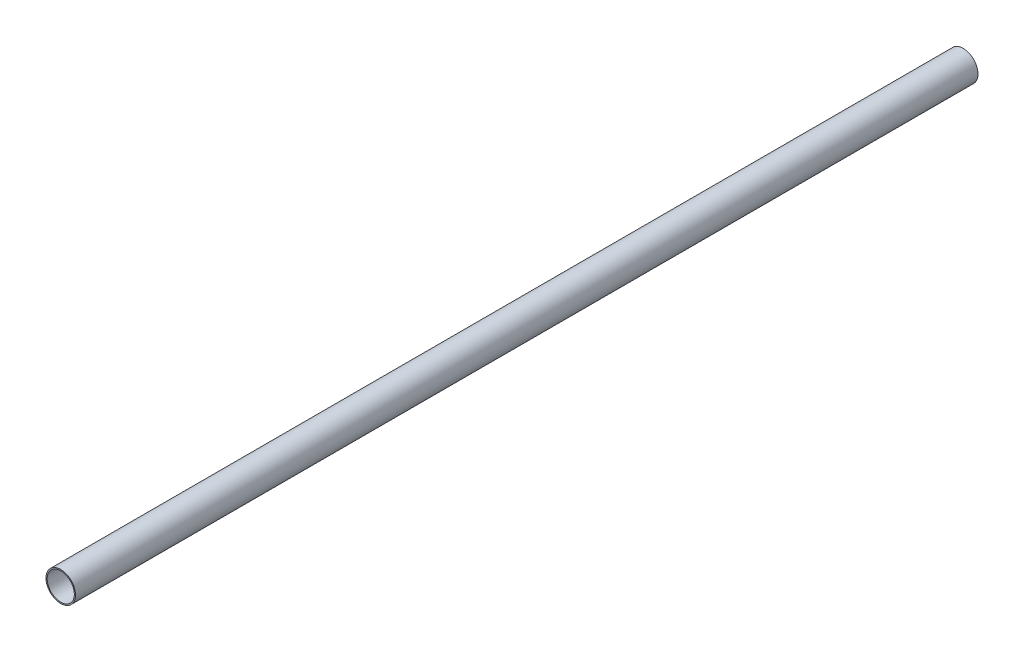
from build123d import *

# Parameters (mm, degrees)
SKETCH1_R           = 13.716
SKETCH1_R_2         = 12.6238
EXTRUDE_THIN1_DEPTH = 419.1


with BuildPart() as part:
    # Sketch1 → Extrude-Thin1 (new body, symmetric)
    with BuildSketch(Plane.XY):
        Circle(SKETCH1_R)
        Circle(SKETCH1_R_2, mode=Mode.SUBTRACT)
    extrude(amount=EXTRUDE_THIN1_DEPTH, both=True)


solid = part.part
